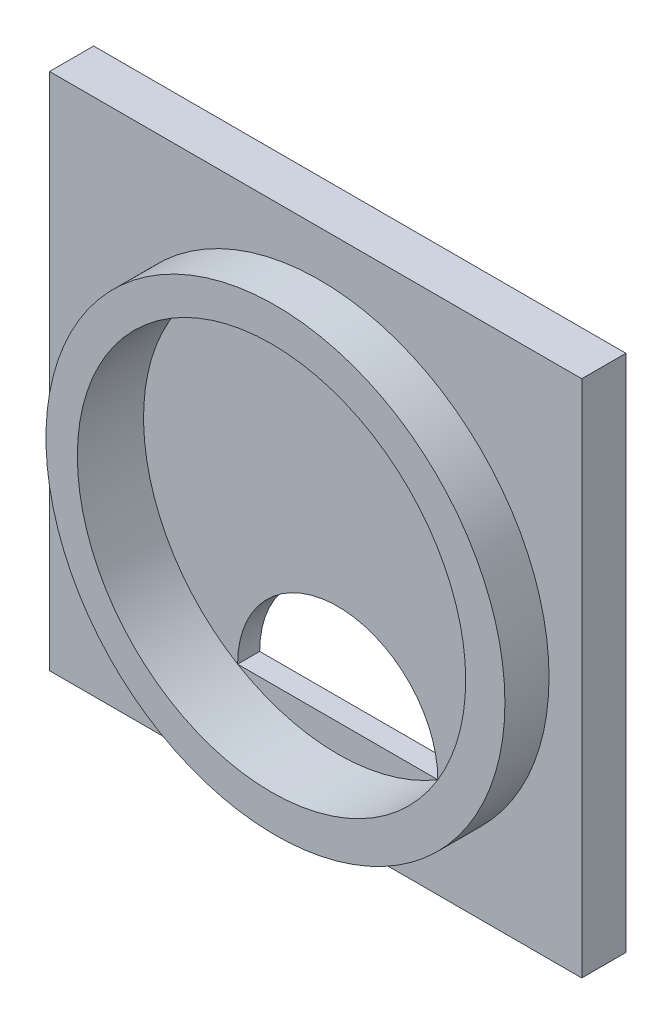
from build123d import *

# Parameters (mm, degrees)
SKETCH16_W          = 60.3
SKETCH16_H          = 58.8
SKETCH16_R          = 22
BOSS_EXTRUDE2_DEPTH = 5
SKETCH22_W          = 60.3
SKETCH22_H          = 2.5
BOSS_EXTRUDE7_DEPTH = 50
SKETCH23_R          = 26
SKETCH23_R_2        = 22
BOSS_EXTRUDE8_DEPTH = 5
CUT_EXTRUDE3_DEPTH  = 2.5
BOSS_EXTRUDE9_DEPTH = 2.5


with BuildPart() as part:
    # Sketch16 → Boss-Extrude2 (new body)
    with BuildSketch(Plane.XY):
        with Locations((0, 1.75)):
            Rectangle(SKETCH16_W, SKETCH16_H)
        Circle(SKETCH16_R, mode=Mode.SUBTRACT)
    extrude(amount=-BOSS_EXTRUDE2_DEPTH)

    # Sketch22 → Boss-Extrude7 (add)
    with BuildSketch(Plane(origin=(0, 31.15, 0), x_dir=(1, 0, 0), z_dir=(0, 1, 0))):
        with Locations((0, 3.75)):
            Rectangle(SKETCH22_W, SKETCH22_H)
    extrude(amount=-BOSS_EXTRUDE7_DEPTH)

    # Sketch23 → Boss-Extrude8 (add)
    with BuildSketch(Plane.XY):
        with Locations((0.443922204, 0)):
            Circle(SKETCH23_R)
        Circle(SKETCH23_R_2, mode=Mode.SUBTRACT)
    extrude(amount=BOSS_EXTRUDE8_DEPTH)

    # Sketch24 → Cut-Extrude3 (cut)
    with BuildSketch(Plane.XY.offset(-2.5)):
        with BuildLine():
            Line((-11.343610536, -18.85), (11.343610536, -18.85))
            ThreePointArc((11.343610536, -18.85), (0, -7.506389464), (-11.343610536, -18.85))
        make_face()
    extrude(amount=-CUT_EXTRUDE3_DEPTH, mode=Mode.SUBTRACT)

    # Sketch25 → Boss-Extrude9 (add)
    with BuildSketch(Plane.XY.offset(-2.5)):
        with BuildLine():
            Line((11.343610536, -18.85), (-11.343610536, -18.85))
            ThreePointArc((-11.343610536, -18.85), (0, -22), (11.343610536, -18.85))
        make_face()
    extrude(amount=-BOSS_EXTRUDE9_DEPTH)


solid = part.part
